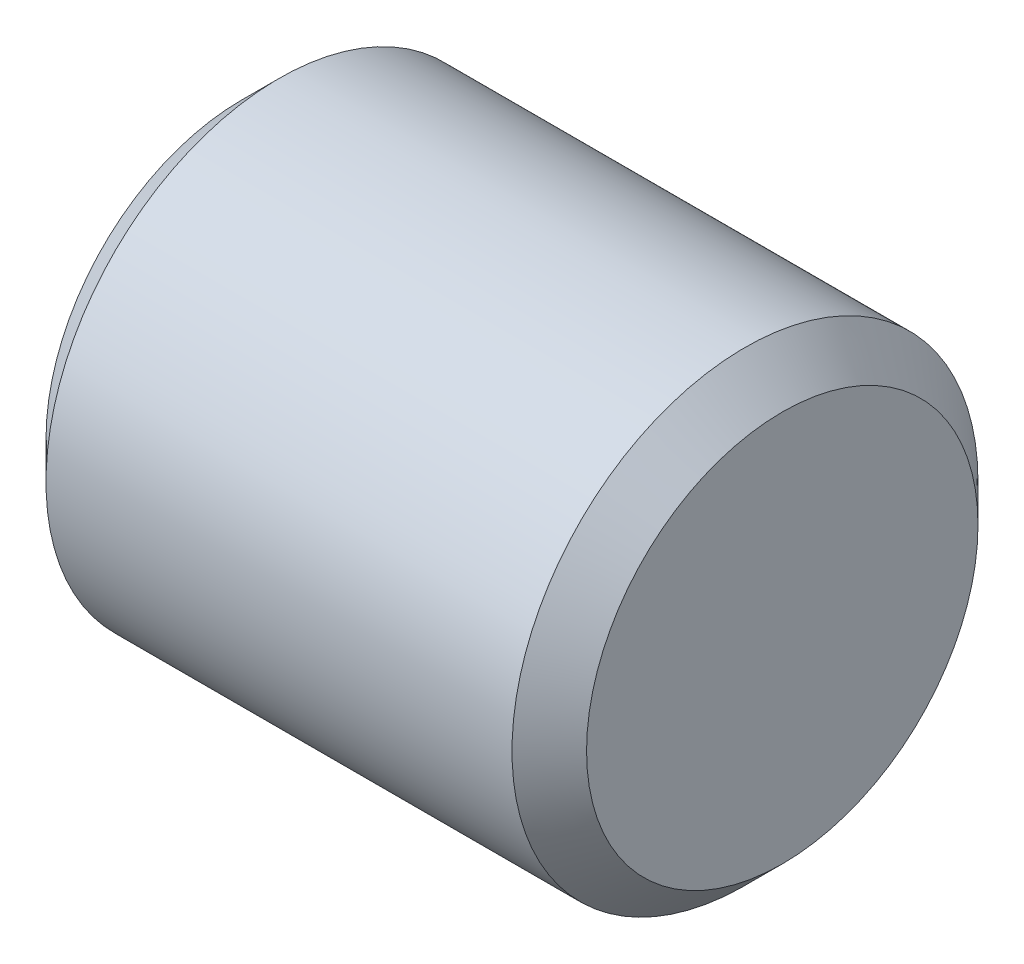
from build123d import *

# Parameters (mm, degrees)
SKETCH2_R           = 7.9375
BOSS_EXTRUDE1_DEPTH = 18.415
CHAMFER1_SIZE       = 1.27
CUT_EXTRUDE2_DEPTH  = 15.24
SKETCH5_R           = 3.81
CUT_EXTRUDE3_DEPTH  = 3.175


with BuildPart() as part:
    # Sketch2 → Boss-Extrude1 (new body)
    with BuildSketch(Plane(origin=(0, 0, 0), x_dir=(0, 0, -1), z_dir=(1, 0, 0))):
        Circle(SKETCH2_R)
    extrude(amount=BOSS_EXTRUDE1_DEPTH)

    # Chamfer1
    chamfer1_edges = [part.edges().sort_by_distance(p)[0] for p in [
        (0, 0, 7.9375),
        (18.415, 0, 7.9375),
    ]]
    chamfer(chamfer1_edges, length=CHAMFER1_SIZE)

    # Sketch4 → Cut-Extrude2 (cut)
    with BuildSketch(Plane.ZY):
        with BuildLine():
            Line((-2.851142929, 1.397), (2.851142929, 1.397))
            ThreePointArc((2.851142929, 1.397), (0, -3.175), (-2.851142929, 1.397))
        make_face()
    extrude(amount=-CUT_EXTRUDE2_DEPTH, mode=Mode.SUBTRACT)

    # Sketch5 → Cut-Extrude3 (cut)
    with BuildSketch(Plane.ZY):
        Circle(SKETCH5_R)
    extrude(amount=-CUT_EXTRUDE3_DEPTH, mode=Mode.SUBTRACT)


solid = part.part
